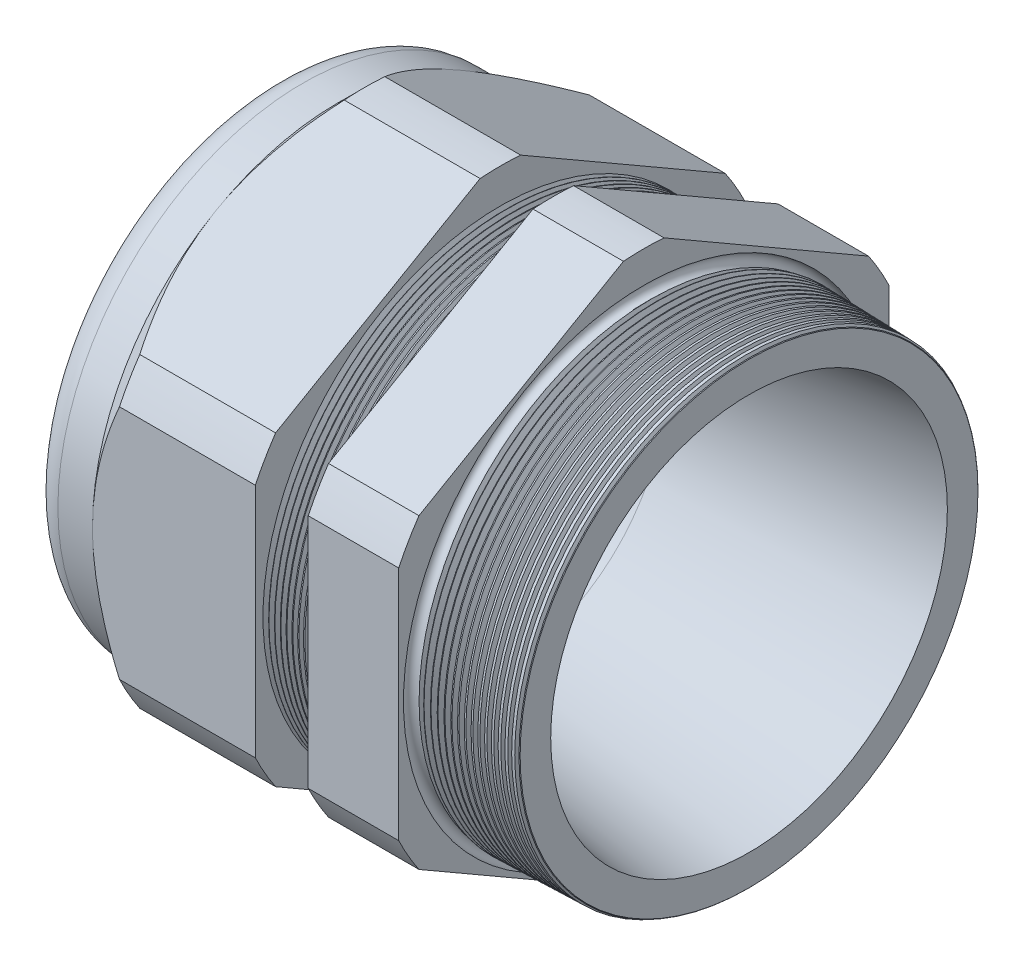
from build123d import *

# Parameters (mm, degrees)
SKETCH12_OUTSIDE_W = 170.928
SKETCH12_OUTSIDE_H = 170.928
CUT_EXTRUDE2_DEPTH = 55.5920168
FILLET4_R          = 3.81
SKETCH19_OUTSIDE_W = 98.176
SKETCH19_OUTSIDE_H = 105.328
SKETCH19_OUTSIDE_R = 32.512
CUT_EXTRUDE3_DEPTH = 3.99796
CUT_EXTRUDE3_DRAFT = -45
CHAMFER1_SIZE      = 0.260919487
CHAMFER1_SIZE2     = 0.254
SKETCH21_R         = 21.971
PLUG_DEPTH         = 12.7
SKETCH22_R         = 21.717
CUT_EXTRUDE4_DEPTH = 0.508
SKETCH27_R         = 5.969
PLUGHOLES_DEPTH    = 63.484
CIRPATTERN1_COUNT  = 6
LPATTERN1_COUNT    = 9
LPATTERN1_PITCH    = 0.762
LPATTERN2_COUNT    = 16
LPATTERN2_PITCH    = 0.889
SKETCH32_R         = 0.889


with BuildPart() as part:
    # Sketch10 → Revolve2 (revolve)
    with BuildSketch(Plane.XY, mode=Mode.PRIVATE) as revolve2_sk:
        Polygon((-56.896, 21.971), (-26.89359112, 21.971), (6.096, 26.314137154), (6.096, 30.632137154), (-7.874, 30.997954479), (-7.874, 65.024), (-19.873976, 65.024), (-19.873976, 31.312184909), (-26.89359112, 31.496), (-26.89359112, 65.024), (-48.4960168, 65.024), (-48.4960168, 32.512), (-56.896, 32.512), align=None)
    revolve(revolve2_sk.sketch.rotate(Axis((0, 0, 0), (-1, 0, 0)), 90), axis=Axis((0, 0, 0), (-1, 0, 0)))  # turned: the seam where the file's is

    # Sketch12 outside → Cut-Extrude2 (cut, through all)
    with BuildSketch(Plane.ZY.offset(48.4960168)):
        Rectangle(SKETCH12_OUTSIDE_W, SKETCH12_OUTSIDE_H)
        with BuildLine():
            Line((-2.69124706, 35.987831689), (-29.82075294, 20.324604167))
            ThreePointArc((-29.82075294, 20.324604167), (-31.2534019, 18.04416), (-32.512, 15.663227523))
            Line((-32.512, 15.663227523), (-32.512, -15.663227523))
            ThreePointArc((-32.512, -15.663227523), (-31.2534019, -18.04416), (-29.82075294, -20.324604167))
            Line((-29.82075294, -20.324604167), (-2.69124706, -35.987831689))
            ThreePointArc((-2.69124706, -35.987831689), (0, -36.08832), (2.69124706, -35.987831689))
            Line((2.69124706, -35.987831689), (29.82075294, -20.324604167))
            ThreePointArc((29.82075294, -20.324604167), (31.2534019, -18.04416), (32.512, -15.663227523))
            Line((32.512, -15.663227523), (32.512, 15.663227523))
            ThreePointArc((32.512, 15.663227523), (31.2534019, 18.04416), (29.82075294, 20.324604167))
            Line((29.82075294, 20.324604167), (2.69124706, 35.987831689))
            ThreePointArc((2.69124706, 35.987831689), (0, 36.08832), (-2.69124706, 35.987831689))
        make_face(mode=Mode.SUBTRACT)
    extrude(amount=-CUT_EXTRUDE2_DEPTH, mode=Mode.SUBTRACT)

    # Fillet4
    fillet4_edges = [part.edges().sort_by_distance(p)[0] for p in [
        (-56.896, 0, 32.512),
    ]]
    fillet(fillet4_edges, radius=FILLET4_R)


with BuildPart() as cut_extrude3_tool:
    # Sketch19 outside → Cut-Extrude3 (with draft: the straight prism first)
    with BuildSketch(Plane.ZY.offset(48.4960168)):
        Rectangle(SKETCH19_OUTSIDE_W, SKETCH19_OUTSIDE_H)
        Circle(SKETCH19_OUTSIDE_R, mode=Mode.SUBTRACT)
    extrude(amount=-CUT_EXTRUDE3_DEPTH)
    # Cut-Extrude3: the draft: its side faces are tilted about the plane it starts from
    cut_extrude3_sides = [cut_extrude3_tool.faces().sort_by_distance(p)[0] for p in [
        (-46.4970368, -52.664, 0),
        (-46.4970368, 0, 49.088),
        (-46.4970368, 52.664, 0),
        (-46.4970368, 0, -49.088),
        (-46.4970368, 0, -32.512),
    ]]
    draft(cut_extrude3_sides, Plane.ZY.offset(48.4960168), CUT_EXTRUDE3_DRAFT)


with BuildPart() as part_1:
    add(part.part)

    # Cut-Extrude3: cut by cut_extrude3_tool
    add(cut_extrude3_tool.part, mode=Mode.SUBTRACT)

    # Chamfer1
    chamfer1_edges = [part_1.edges().sort_by_distance(p)[0] for p in [
        (6.096, 0, 30.632137154),
    ]]
    chamfer1_side = [part_1.faces().sort_by_distance(p)[0] for p in [
        (6.096, 0, 27.18054483),
    ]]
    chamfer(chamfer1_edges, length=CHAMFER1_SIZE, length2=CHAMFER1_SIZE2, reference=chamfer1_side[0])

    # Sketch29 → Cut-Revolve1 (revolve, cut)
    with BuildSketch(Plane.XY, mode=Mode.PRIVATE) as cut_revolve1_sk:
        Polygon((-26.89359112, 31.496), (-26.160607539, 31.476806149), (-26.543721692, 30.851620673), align=None)
    cut_revolve1 = revolve(cut_revolve1_sk.sketch.rotate(Axis((0, 0, 0), (-1, 0, 0)), 90), axis=Axis((0, 0, 0), (-1, 0, 0)), mode=Mode.SUBTRACT)  # turned: the seam where the file's is

    # LPattern1: Cut-Revolve1 ×9
    with Locations(*[(i * LPATTERN1_PITCH, 0, 0) for i in range(1, LPATTERN1_COUNT)]):
        add(cut_revolve1, mode=Mode.SUBTRACT)

    # Sketch30 → Cut-Revolve2 (revolve, cut)
    with BuildSketch(Plane.XY, mode=Mode.PRIVATE) as cut_revolve2_sk:
        Polygon((-7.874, 30.997954479), (-6.994419703, 30.974921858), (-7.454156686, 30.224699287), align=None)
    cut_revolve2 = revolve(cut_revolve2_sk.sketch.rotate(Axis((0, 0, 0), (-1, 0, 0)), 270), axis=Axis((0, 0, 0), (-1, 0, 0)), mode=Mode.SUBTRACT)  # turned: the seam where the file's is

    # LPattern2: Cut-Revolve2 ×16
    with Locations(*[(i * LPATTERN2_PITCH, 0, 0) for i in range(1, LPATTERN2_COUNT)]):
        add(cut_revolve2, mode=Mode.SUBTRACT)

    # Sketch32 → Cut-Revolve3 (revolve, cut)
    with BuildSketch(Plane.XY, mode=Mode.PRIVATE) as cut_revolve3_sk:
        with Locations((-7.747, 30.997954479)):
            Circle(SKETCH32_R)
    revolve(cut_revolve3_sk.sketch.rotate(Axis((0, 0, 0), (-1, 0, 0)), 270), axis=Axis((0, 0, 0), (-1, 0, 0)), mode=Mode.SUBTRACT)  # turned: the seam where the file's is


with BuildPart() as body_2:
    # Sketch21 → plug (new body)
    with BuildSketch(Plane.ZY.offset(56.896)):
        Circle(SKETCH21_R)
    extrude(amount=-PLUG_DEPTH)

    # Sketch22 → Cut-Extrude4 (cut)
    with BuildSketch(Plane.ZY.offset(56.896)):
        Circle(SKETCH22_R)
    extrude(amount=-CUT_EXTRUDE4_DEPTH, mode=Mode.SUBTRACT)

    # Sketch27 → plugholes (cut, through all)
    with BuildSketch(Plane.ZY.offset(56.388)):
        with Locations((-15.724124, 0)):
            Circle(SKETCH27_R)
    plugholes = extrude(amount=-PLUGHOLES_DEPTH, mode=Mode.SUBTRACT)

    # CirPattern1: plugholes ×6 about axis
    cirpattern1_axis = Axis((0, 0, 0), (1, 0, 0))
    for i in range(1, CIRPATTERN1_COUNT):
        add(plugholes.rotate(cirpattern1_axis, i * 360 / CIRPATTERN1_COUNT), mode=Mode.SUBTRACT)


solid = Compound([part_1.part, body_2.part])
